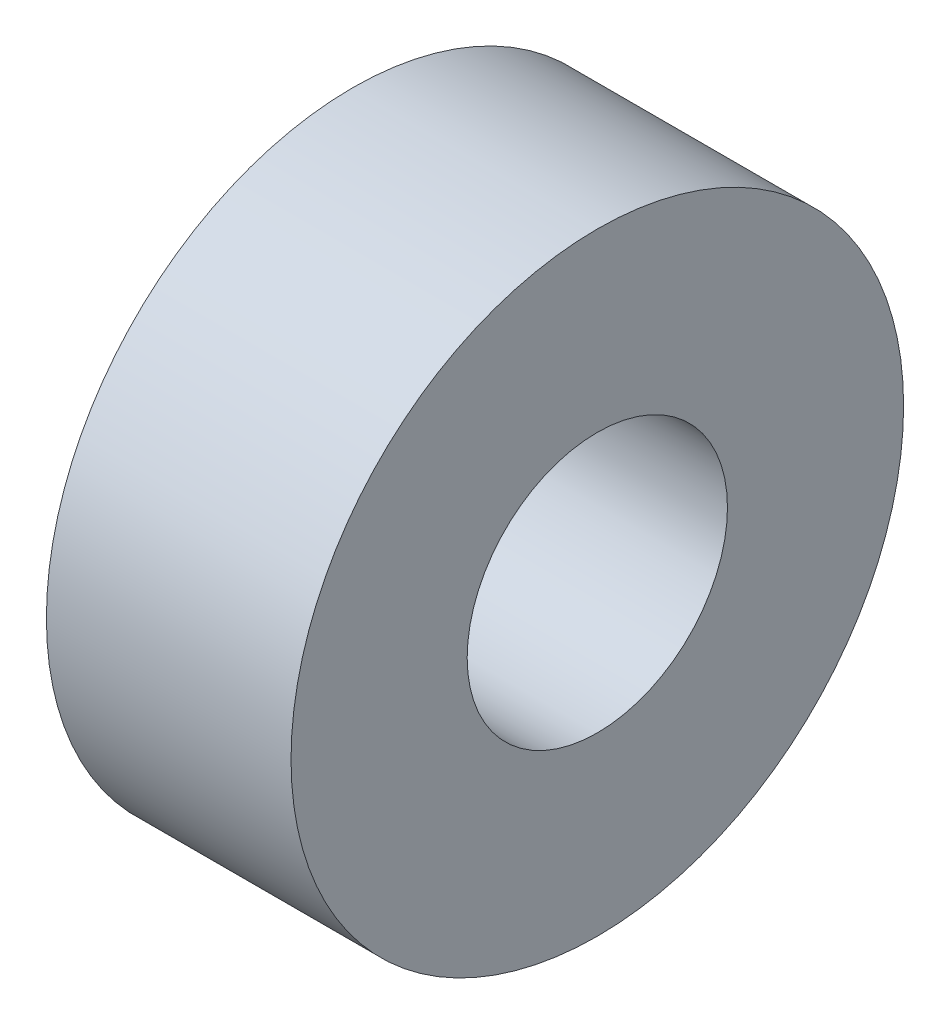
from build123d import *

# Parameters (mm, degrees)
SKETCH1_R           = 7.9502
SKETCH1_R_2         = 3.3782
BOSS_EXTRUDE1_DEPTH = 6.35


with BuildPart() as part:
    # Sketch1 → Boss-Extrude1 (new body)
    with BuildSketch(Plane(origin=(0, 0, 0), x_dir=(0, 0, -1), z_dir=(1, 0, 0))):
        Circle(SKETCH1_R)
        Circle(SKETCH1_R_2, mode=Mode.SUBTRACT)
    extrude(amount=BOSS_EXTRUDE1_DEPTH)


solid = part.part
